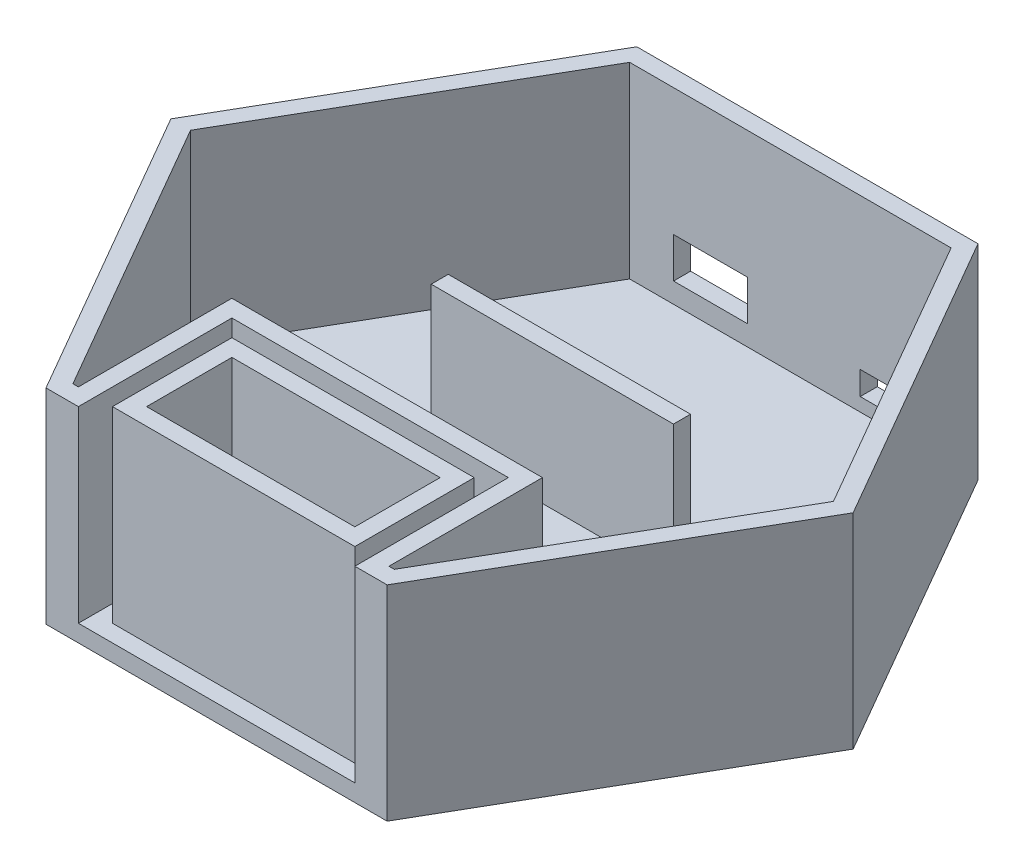
from build123d import *

# Parameters (mm, degrees)
BOSS_EXTRUDE1_DEPTH = 2.54
SKETCH3_W           = 36.089649417
SKETCH3_H           = 17.78
SKETCH3_W_2         = 31.009649417
SKETCH3_H_2         = 12.7
BOSS_EXTRUDE2_DEPTH = 30.48
SKETCH5_W           = 36.077770682
SKETCH5_H           = 2.54
BOSS_EXTRUDE3_DEPTH = 20
SKETCH7_W           = 9
SKETCH7_H           = 3.5
SKETCH7_W_2         = 11
SKETCH7_H_2         = 6
CUT_EXTRUDE1_DEPTH  = 3.54


with BuildPart() as part:
    # Sketch2 → Boss-Extrude1 (new body)
    with BuildSketch(Plane(origin=(0, 0, 0), x_dir=(1, 0, 0), z_dir=(0, 1, 0))):
        Polygon((76.2, 0), (101.6, 43.994090512), (76.2, 87.988181024), (25.4, 87.988181024), (0, 43.994090512), (25.4, 0), align=None)
    extrude(amount=BOSS_EXTRUDE1_DEPTH)

    # Sketch3 → Boss-Extrude2 (add)
    with BuildSketch(Plane(origin=(0, 0, 0), x_dir=(1, 0, 0), z_dir=(0, 1, 0))):
        with Locations((50.805939368, 11.43)):
            Rectangle(SKETCH3_W, SKETCH3_H)
        with Locations((50.805939368, 11.43)):
            Rectangle(SKETCH3_W_2, SKETCH3_H_2, mode=Mode.SUBTRACT)
        Polygon((30.221114659, 22.86), (30.221114659, 0), (25.4, 0), (0, 43.994090512), (25.4, 87.988181024), (76.2, 87.988181024), (101.6, 43.994090512), (76.2, 0), (71.390764076, 0), (71.390764076, 22.86), align=None)
        Polygon((73.930764076, 2.54), (74.733530316, 2.54), (98.667060633, 43.994090512), (74.733530316, 85.448181024), (26.866469684, 85.448181024), (2.932939367, 43.994090512), (26.866469684, 2.54), (27.681114659, 2.54), (27.681114659, 25.4), (73.930764076, 25.4), align=None, mode=Mode.SUBTRACT)
    extrude(amount=BOSS_EXTRUDE2_DEPTH)

    # Sketch5 → Boss-Extrude3 (add)
    with BuildSketch(Plane(origin=(0, 2.54, 0), x_dir=(1, 0, 0), z_dir=(0, 1, 0))):
        with Locations((50.8, 51.27)):
            Rectangle(SKETCH5_W, SKETCH5_H)
    extrude(amount=BOSS_EXTRUDE3_DEPTH)

    # Sketch7 → Cut-Extrude1 (cut, through all)
    with BuildSketch(Plane.XY.offset(-85.448181024)):
        with Locations((65.7, 6.29)):
            Rectangle(SKETCH7_W, SKETCH7_H)
        with Locations((38.9, 8.54)):
            Rectangle(SKETCH7_W_2, SKETCH7_H_2)
    extrude(amount=-CUT_EXTRUDE1_DEPTH, mode=Mode.SUBTRACT)


solid = part.part
